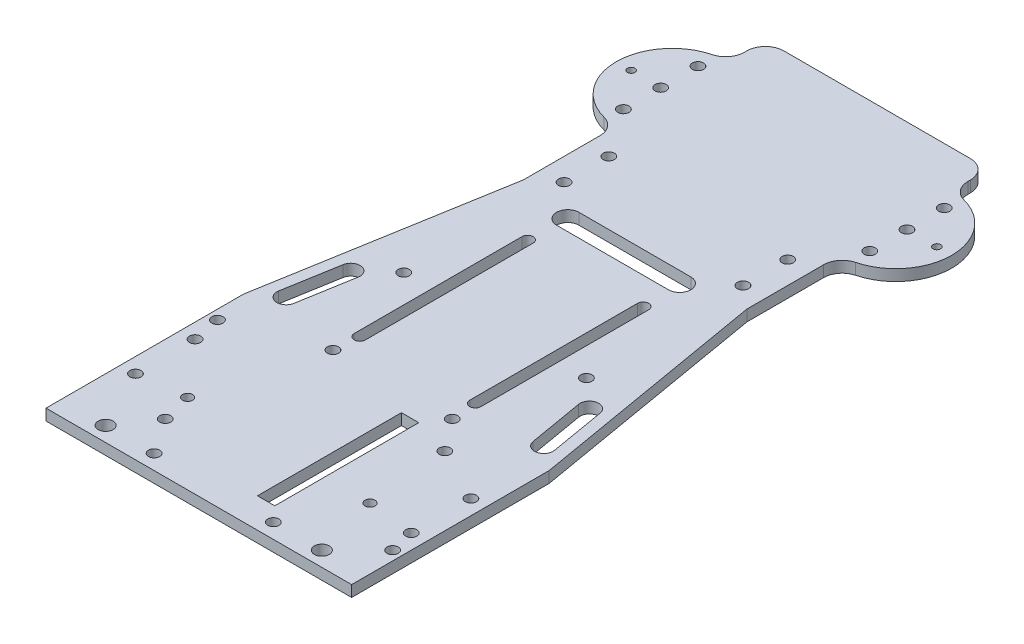
from build123d import *

# Parameters (mm, degrees)
BOSS_EXTRUDE1_DEPTH  = 3
BOSS_EXTRUDE2_DEPTH  = 60
BOSS_EXTRUDE3_DEPTH  = 3
SKETCH4_R            = 1.5
CUT_EXTRUDE1_DEPTH   = 4
LPATTERN1_COUNT      = 2
LPATTERN1_PITCH      = 48
LPATTERN1_COUNT_DIR2 = 2
LPATTERN1_PITCH_DIR2 = 12
SKETCH6_W            = 23.651553975
SKETCH6_H            = 52.455294706
CUT_EXTRUDE2_DEPTH   = 4
SKETCH8_W            = 46.628396315
SKETCH8_H            = 3
BOSS_EXTRUDE4_DEPTH  = 19
SKETCH9_W            = 8
SKETCH9_H            = 3
BOSS_EXTRUDE5_DEPTH  = 4.651554
SKETCH12_R           = 1.5
CUT_EXTRUDE4_DEPTH   = 17
SKETCH13_R           = 1
SKETCH13_R_2         = 1.5
CUT_EXTRUDE5_DEPTH   = 4
SKETCH14_R           = 1.35
CUT_EXTRUDE6_DEPTH   = 17
SKETCH15_R           = 1.5
CUT_EXTRUDE7_DEPTH   = 17
SKETCH16_R           = 1.5
CUT_EXTRUDE8_DEPTH   = 17
CUT_EXTRUDE9_DEPTH   = 17
SKETCH19_R           = 1.5
CUT_EXTRUDE10_DEPTH  = 17
CUT_EXTRUDE11_START  = -65.281828
SKETCH20_W           = 42
SKETCH20_H           = 16
CUT_EXTRUDE11_DEPTH  = 70.563656
FILLET1_R            = 5
FILLET2_R            = 5
SKETCH21_R           = 1.5
CUT_EXTRUDE12_DEPTH  = 4
CUT_EXTRUDE13_DEPTH  = 4
SKETCH23_R           = 1.5
CUT_EXTRUDE14_DEPTH  = 4
CUT_EXTRUDE15_DEPTH  = 4
SKETCH25_R           = 2
CUT_EXTRUDE16_DEPTH  = 4


with BuildPart() as part:
    # Sketch1 → Boss-Extrude1 (new body)
    with BuildSketch(Plane(origin=(0, 0, 0), x_dir=(1, 0, 0), z_dir=(0, 1, 0))):
        with BuildLine():
            Line((-41, 0), (41, 0))
            Line((41, 0), (41, 53))
            Line((41, 53), (30, 117.062469512))
            Line((30, 117.062469512), (30, 137.635083269))
            ThreePointArc((30, 137.635083269), (31.047152925, 140.696945447), (33.75, 142.476312452))
            ThreePointArc((33.75, 142.476312452), (45, 157), (33.75, 171.523687548))
            ThreePointArc((33.75, 171.523687548), (31.047152925, 173.303054553), (30, 176.364916731))
            Line((30, 176.364916731), (30, 182))
            Line((30, 182), (-30, 182))
            Line((-30, 182), (-30, 176.364916731))
            ThreePointArc((-30, 176.364916731), (-31.047152925, 173.303054553), (-33.75, 171.523687548))
            ThreePointArc((-33.75, 171.523687548), (-45, 157), (-33.75, 142.476312452))
            ThreePointArc((-33.75, 142.476312452), (-31.047152925, 140.696945447), (-30, 137.635083269))
            Line((-30, 137.635083269), (-30, 117.062469512))
            Line((-30, 117.062469512), (-41, 53))
            Line((-41, 53), (-41, 0))
        make_face()
    extrude(amount=BOSS_EXTRUDE1_DEPTH)

    # Sketch4 → Cut-Extrude1 (cut, through all)
    with BuildSketch(Plane(origin=(0, 3, 0), x_dir=(1, 0, 0), z_dir=(0, 1, 0))):
        with Locations((-24, 134)):
            Circle(SKETCH4_R)
    cut_extrude1 = extrude(amount=-CUT_EXTRUDE1_DEPTH, mode=Mode.SUBTRACT)

    # LPattern1: Cut-Extrude1 2 × 2
    with Locations(*[(i * LPATTERN1_PITCH, 0, j * LPATTERN1_PITCH_DIR2) for i in range(LPATTERN1_COUNT) for j in range(LPATTERN1_COUNT_DIR2) if (i, j) != (0, 0)]):
        add(cut_extrude1, mode=Mode.SUBTRACT)

    # Sketch6 → Cut-Extrude2 (cut, through all)
    with BuildSketch(Plane(origin=(0, 3, 0), x_dir=(1, 0, 0), z_dir=(0, 1, 0))):
        with Locations((0.55948687, 20.400748962)):
            Rectangle(SKETCH6_W, SKETCH6_H)
    extrude(amount=-CUT_EXTRUDE2_DEPTH, mode=Mode.SUBTRACT)

    # Sketch8 → Boss-Extrude4 (add)
    with BuildSketch(Plane(origin=(-11.266290117, 0, 0), x_dir=(0, 0, -1), z_dir=(1, 0, 0))):
        with Locations((23.314198158, 1.5)):
            Rectangle(SKETCH8_W, SKETCH8_H)
    extrude(amount=BOSS_EXTRUDE4_DEPTH)

    # Sketch9 → Boss-Extrude5 (add)
    with BuildSketch(Plane(origin=(7.733709883, 0, 0), x_dir=(0, 0, -1), z_dir=(1, 0, 0))):
        with Locations((4, 1.5)):
            Rectangle(SKETCH9_W, SKETCH9_H)
    extrude(amount=BOSS_EXTRUDE5_DEPTH)

    # Sketch12 → Cut-Extrude4 (cut, through all)
    with BuildSketch(Plane.XZ):
        with Locations((-16, -4)):
            Circle(SKETCH12_R)
        with Locations((16, -4)):
            Circle(SKETCH12_R)
    extrude(amount=-CUT_EXTRUDE4_DEPTH, mode=Mode.SUBTRACT)

    # Sketch13 → Cut-Extrude5 (cut, through all)
    with BuildSketch(Plane(origin=(0, 3, 0), x_dir=(1, 0, 0), z_dir=(0, 1, 0))):
        with Locations((41, 157)):
            Circle(SKETCH13_R)
        with Locations((-41, 157)):
            Circle(SKETCH13_R)
        with Locations((33, 157)):
            Circle(SKETCH13_R_2)
        with Locations((-33, 156.913211427)):
            Circle(SKETCH13_R_2)
        with Locations((33, 147)):
            Circle(SKETCH13_R_2)
        with Locations((33, 167)):
            Circle(SKETCH13_R_2)
        with Locations((-33, 166.913211427)):
            Circle(SKETCH13_R_2)
        with Locations((-33, 146.913211427)):
            Circle(SKETCH13_R_2)
    extrude(amount=-CUT_EXTRUDE5_DEPTH, mode=Mode.SUBTRACT)

    # Sketch14 → Cut-Extrude6 (cut, through all)
    with BuildSketch(Plane.XZ):
        with Locations((-24.5, -21.5)):
            Circle(SKETCH14_R)
        with Locations((24.54, -21.4)):
            Circle(SKETCH14_R)
    extrude(amount=-CUT_EXTRUDE6_DEPTH, mode=Mode.SUBTRACT)

    # Sketch15 → Cut-Extrude7 (cut, through all)
    with BuildSketch(Plane.XZ):
        with Locations((22.5, -43.5)):
            Circle(SKETCH15_R)
        with Locations((38.5, -13.5)):
            Circle(SKETCH15_R)
    extrude(amount=-CUT_EXTRUDE7_DEPTH, mode=Mode.SUBTRACT)

    # Sketch16 → Cut-Extrude8 (cut, through all)
    with BuildSketch(Plane.XZ):
        with Locations((-22.5, -13.5)):
            Circle(SKETCH16_R)
        with Locations((-38.5, -43.5)):
            Circle(SKETCH16_R)
    extrude(amount=-CUT_EXTRUDE8_DEPTH, mode=Mode.SUBTRACT)

    # Sketch17 → Cut-Extrude9 (cut, through all)
    with BuildSketch(Plane.XZ):
        with BuildLine():
            Line((37.02491368, -58.423076923), (34.486452142, -73.206723734))
            ThreePointArc((34.486452142, -73.206723734), (31.599434084, -75.247587946), (29.558569872, -72.360569887))
            Line((29.558569872, -72.360569887), (32.09703141, -57.576923077))
            ThreePointArc((32.09703141, -57.576923077), (34.984049468, -55.536058865), (37.02491368, -58.423076923))
        make_face()
        with BuildLine():
            Line((-37.02491368, -58.423076923), (-34.486452142, -73.206723734))
            ThreePointArc((-34.486452142, -73.206723734), (-31.599434084, -75.247587946), (-29.558569872, -72.360569887))
            Line((-29.558569872, -72.360569887), (-32.09703141, -57.576923077))
            ThreePointArc((-32.09703141, -57.576923077), (-34.984049468, -55.536058865), (-37.02491368, -58.423076923))
        make_face()
    extrude(amount=-CUT_EXTRUDE9_DEPTH, mode=Mode.SUBTRACT)

    # Sketch19 → Cut-Extrude10 (cut, through all)
    with BuildSketch(Plane(origin=(0, 0, 0), x_dir=(-1, 0, 0), z_dir=(0, -1, 0))):
        with Locations((24.5, 79.5)):
            Circle(SKETCH19_R)
        with Locations((-24.5, 79.5)):
            Circle(SKETCH19_R)
    extrude(amount=-CUT_EXTRUDE10_DEPTH, mode=Mode.SUBTRACT)

    # Fillet1
    fillet1_edges = [part.edges().sort_by_distance(p)[0] for p in [
        (30, 1.5, -182),
    ]]
    fillet(fillet1_edges, radius=FILLET1_R)

    # Fillet2
    fillet2_edges = [part.edges().sort_by_distance(p)[0] for p in [
        (-30, 1.5, -182),
    ]]
    fillet(fillet2_edges, radius=FILLET2_R)

    # Sketch21 → Cut-Extrude12 (cut, through all)
    with BuildSketch(Plane(origin=(0, 3, 0), x_dir=(1, 0, 0), z_dir=(0, 1, 0))):
        with Locations((37, 20)):
            Circle(SKETCH21_R)
        with Locations((-37, 20)):
            Circle(SKETCH21_R)
        with Locations((-37, 36)):
            Circle(SKETCH21_R)
        with Locations((37, 36)):
            Circle(SKETCH21_R)
    extrude(amount=-CUT_EXTRUDE12_DEPTH, mode=Mode.SUBTRACT)

    # Sketch22 → Cut-Extrude13 (cut, through all)
    with BuildSketch(Plane(origin=(0, 3, 0), x_dir=(1, 0, 0), z_dir=(0, 1, 0))):
        with BuildLine():
            Line((14, 58.7), (14, 103.7))
            ThreePointArc((14, 103.7), (15.5, 105.2), (17, 103.7))
            Line((17, 103.7), (17, 58.7))
            ThreePointArc((17, 58.7), (15.5, 57.2), (14, 58.7))
        make_face()
        with BuildLine():
            Line((-17, 58.7), (-17, 103.7))
            ThreePointArc((-17, 103.7), (-15.5, 105.2), (-14, 103.7))
            Line((-14, 103.7), (-14, 58.7))
            ThreePointArc((-14, 58.7), (-15.5, 57.2), (-17, 58.7))
        make_face()
    extrude(amount=-CUT_EXTRUDE13_DEPTH, mode=Mode.SUBTRACT)

    # Sketch23 → Cut-Extrude14 (cut, through all)
    with BuildSketch(Plane(origin=(0, 3, 0), x_dir=(1, 0, 0), z_dir=(0, 1, 0))):
        with Locations((-16, 52)):
            Circle(SKETCH23_R)
        with Locations((16, 52)):
            Circle(SKETCH23_R)
    extrude(amount=-CUT_EXTRUDE14_DEPTH, mode=Mode.SUBTRACT)

    # Sketch24 → Cut-Extrude15 (cut, through all)
    with BuildSketch(Plane(origin=(0, 3, 0), x_dir=(1, 0, 0), z_dir=(0, 1, 0))):
        with BuildLine():
            Line((15, 111), (-15, 111))
            ThreePointArc((-15, 111), (-18, 114), (-15, 117))
            Line((-15, 117), (15, 117))
            ThreePointArc((15, 117), (18, 114), (15, 111))
        make_face()
    extrude(amount=-CUT_EXTRUDE15_DEPTH, mode=Mode.SUBTRACT)

    # Sketch25 → Cut-Extrude16 (cut, through all)
    with BuildSketch(Plane(origin=(0, 3, 0), x_dir=(1, 0, 0), z_dir=(0, 1, 0))):
        with Locations((-29, 4)):
            Circle(SKETCH25_R)
        with Locations((29, 4)):
            Circle(SKETCH25_R)
    extrude(amount=-CUT_EXTRUDE16_DEPTH, mode=Mode.SUBTRACT)


with BuildPart() as body_2:
    # Sketch2 → Boss-Extrude2 (new body)
    with BuildSketch(Plane.ZY.offset(30)):
        Polygon((-182, 0), (-196, 13), (-196, 16), (-182, 3), align=None)
    extrude(amount=-BOSS_EXTRUDE2_DEPTH)

    # Sketch3 → Boss-Extrude3 (add)
    with BuildSketch(Plane(origin=(0, 16, 0), x_dir=(1, 0, 0), z_dir=(0, 1, 0))):
        with BuildLine():
            Line((-30, 196), (30, 196))
            Line((30, 196), (34.802113349, 210.939908196))
            ThreePointArc((34.802113349, 210.939908196), (33.362697678, 219.890631628), (25.281827736, 224))
            Line((25.281827736, 224), (-25.281827736, 224))
            ThreePointArc((-25.281827736, 224), (-33.362697678, 219.890631628), (-34.802113349, 210.939908196))
            Line((-34.802113349, 210.939908196), (-30, 196))
        make_face()
    extrude(amount=-BOSS_EXTRUDE3_DEPTH)

    # Sketch20 → Cut-Extrude11 (cut)
    with BuildSketch(Plane(origin=(30, 0, 0), x_dir=(0, 0, -1), z_dir=(1, 0, 0)).offset(CUT_EXTRUDE11_START)):
        with Locations((203, 8)):
            Rectangle(SKETCH20_W, SKETCH20_H)
    extrude(amount=CUT_EXTRUDE11_DEPTH, mode=Mode.SUBTRACT)


solid = part.part
